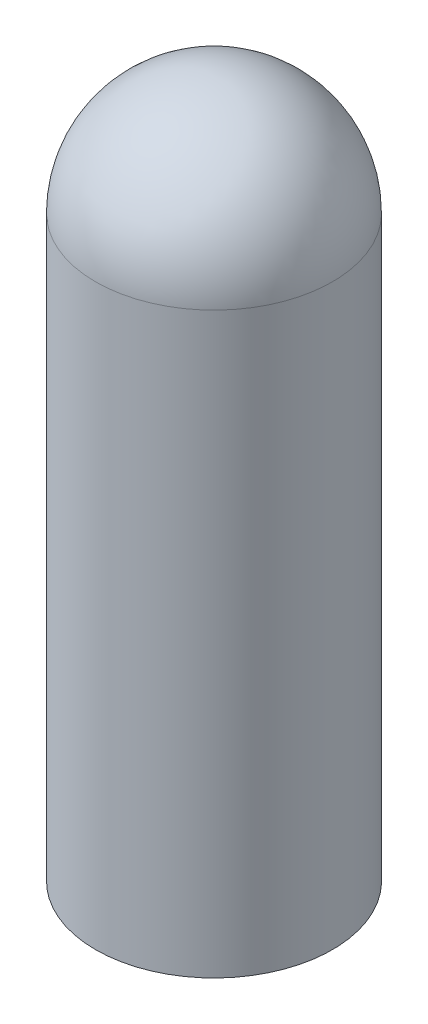
from build123d import *

# Parameters (mm, degrees)
SKETCH2_R           = 21.59
BOSS_EXTRUDE1_DEPTH = 144.78
SKETCH3_R           = 19.05
CUT_EXTRUDE1_DEPTH  = 139.7
FILLET1_R           = 21.59
FILLET2_R           = 19.05
SKETCH4_R           = 21.59
CUT_EXTRUDE2_DEPTH  = 17.78


with BuildPart() as part:
    # Sketch2 → Boss-Extrude1 (new body)
    with BuildSketch(Plane(origin=(0, 0, 0), x_dir=(1, 0, 0), z_dir=(0, 1, 0))):
        Circle(SKETCH2_R)
    extrude(amount=BOSS_EXTRUDE1_DEPTH)

    # Sketch3 → Cut-Extrude1 (cut)
    with BuildSketch(Plane.XZ):
        Circle(SKETCH3_R)
    extrude(amount=-CUT_EXTRUDE1_DEPTH, mode=Mode.SUBTRACT)

    # Fillet1
    fillet1_edges = [part.edges().sort_by_distance(p)[0] for p in [
        (-21.59, 144.78, 0),
    ]]
    fillet(fillet1_edges, radius=FILLET1_R)

    # Fillet2
    fillet2_edges = [part.edges().sort_by_distance(p)[0] for p in [
        (-19.05, 139.7, 0),
    ]]
    fillet(fillet2_edges, radius=FILLET2_R)

    # Sketch4 → Cut-Extrude2 (cut)
    with BuildSketch(Plane.XZ):
        Circle(SKETCH4_R)
    extrude(amount=-CUT_EXTRUDE2_DEPTH, mode=Mode.SUBTRACT)


solid = part.part
